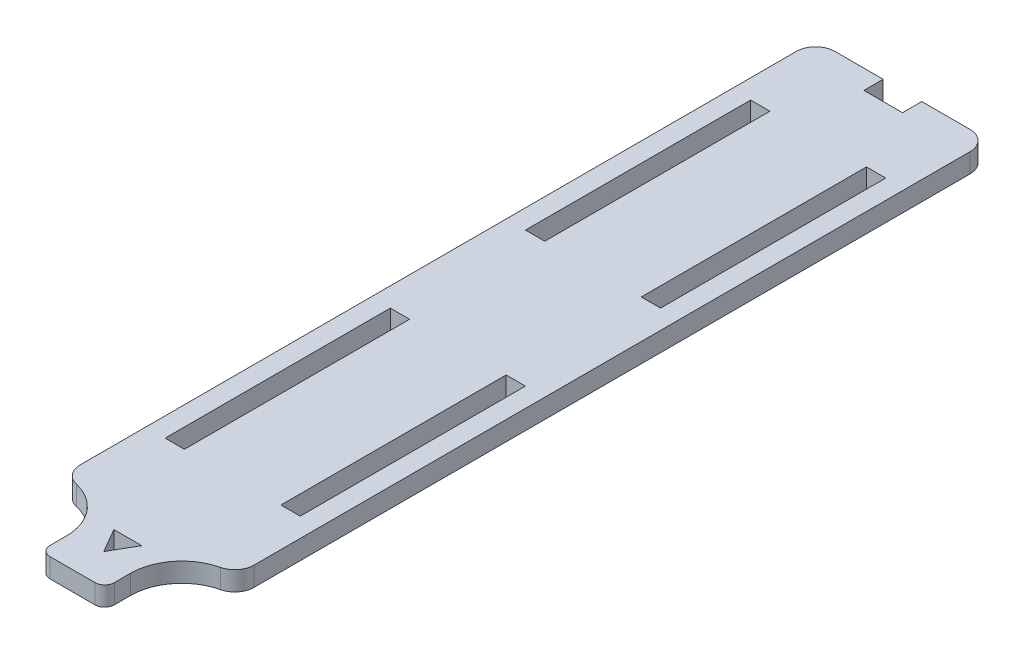
from build123d import *

# Parameters (mm, degrees)
SKETCH1_W               = 27
SKETCH1_H               = 129
BOSS_EXTRUDE1_DEPTH     = 1.5
FILLET1_R               = 3
SKETCH3_W               = 6
SKETCH3_H               = 3
CUT_EXTRUDE2_DEPTH      = 2.5
CUT_EXTRUDE2_DEPTH_BACK = 2.5
CUT_EXTRUDE4_DEPTH      = 2.5
CUT_EXTRUDE4_DEPTH_BACK = 2.5
FILLET2_R               = 3
FILLET2_2_R             = 1.5
CUT_EXTRUDE3_DEPTH      = 5
SKETCH2_W               = 3
SKETCH2_H               = 35
CUT_EXTRUDE1_DEPTH      = 2.5000001
CUT_EXTRUDE1_DEPTH_BACK = 2.5000001


with BuildPart() as part:
    # Sketch1 → Boss-Extrude1 (new body, symmetric)
    with BuildSketch(Plane(origin=(0, 0, 0), x_dir=(1, 0, 0), z_dir=(0, 1, 0))):
        Rectangle(SKETCH1_W, SKETCH1_H)
    extrude(amount=BOSS_EXTRUDE1_DEPTH, both=True)

    # Fillet1
    fillet1_edges = [part.edges().sort_by_distance(p)[0] for p in [
        (-13.5, 0, -64.5),
        (13.5, 0, -64.5),
    ]]
    fillet(fillet1_edges, radius=FILLET1_R)

    # Sketch3 → Cut-Extrude2 (cut, two sides)
    with BuildSketch(Plane(origin=(0, 0, 0), x_dir=(1, 0, 0), z_dir=(0, 1, 0))) as cut_extrude2_sk:
        with Locations((0, 63)):
            Rectangle(SKETCH3_W, SKETCH3_H)
    extrude(amount=CUT_EXTRUDE2_DEPTH, mode=Mode.SUBTRACT)
    extrude(cut_extrude2_sk.sketch, amount=-CUT_EXTRUDE2_DEPTH_BACK, mode=Mode.SUBTRACT)

    # Sketch5 → Cut-Extrude4 (cut, two sides)
    with BuildSketch(Plane(origin=(0, 0, 0), x_dir=(1, 0, 0), z_dir=(0, 1, 0))) as cut_extrude4_sk:
        with BuildLine():
            Line((-13.5, -52.5), (-13, -52.5))
            ThreePointArc((-13, -52.5), (-7.343145751, -54.843145751), (-5, -60.5))
            Line((-5, -60.5), (-5, -64.5))
            Line((-5, -64.5), (-13.5, -64.5))
            Line((-13.5, -64.5), (-13.5, -52.5))
        make_face()
        with BuildLine():
            Line((5, -60.5), (5, -64.5))
            Line((5, -64.5), (13.5, -64.5))
            Line((13.5, -64.5), (13.5, -52.5))
            Line((13.5, -52.5), (13, -52.5))
            ThreePointArc((13, -52.5), (7.343145751, -54.843145751), (5, -60.5))
        make_face()
    extrude(amount=CUT_EXTRUDE4_DEPTH, mode=Mode.SUBTRACT)
    extrude(cut_extrude4_sk.sketch, amount=-CUT_EXTRUDE4_DEPTH_BACK, mode=Mode.SUBTRACT)

    # Fillet2
    fillet2_edges = [part.edges().sort_by_distance(p)[0] for p in [
        (-13.5, 0, 52.5),
        (13.5, 0, 52.5),
    ]]
    fillet(fillet2_edges, radius=FILLET2_R)

    # Fillet2 2
    fillet2_2_edges = [part.edges().sort_by_distance(p)[0] for p in [
        (-5, 0, 64.5),
        (5, 0, 64.5),
    ]]
    fillet(fillet2_2_edges, radius=FILLET2_2_R)

    # Sketch4 → Cut-Extrude3 (cut, symmetric)
    with BuildSketch(Plane(origin=(0, 0, 0), x_dir=(1, 0, 0), z_dir=(0, 1, 0))):
        Polygon((0, -59.643928679), (2.165063509, -55.893928679), (-2.165063509, -55.893928679), align=None)
    extrude(amount=CUT_EXTRUDE3_DEPTH, both=True, mode=Mode.SUBTRACT)

    # Sketch2 → Cut-Extrude1 (cut, two sides)
    with BuildSketch(Plane(origin=(0, 0, 0), x_dir=(1, 0, 0), z_dir=(0, 1, 0))) as cut_extrude1_sk:
        with Locations((-9, 33.895)):
            Rectangle(SKETCH2_W, SKETCH2_H)
        with Locations((9, 33.895)):
            Rectangle(SKETCH2_W, SKETCH2_H)
        with Locations((9, -22.105)):
            Rectangle(SKETCH2_W, SKETCH2_H)
        with Locations((-9, -22.105)):
            Rectangle(SKETCH2_W, SKETCH2_H)
    extrude(amount=CUT_EXTRUDE1_DEPTH, mode=Mode.SUBTRACT)
    extrude(cut_extrude1_sk.sketch, amount=-CUT_EXTRUDE1_DEPTH_BACK, mode=Mode.SUBTRACT)


solid = part.part
